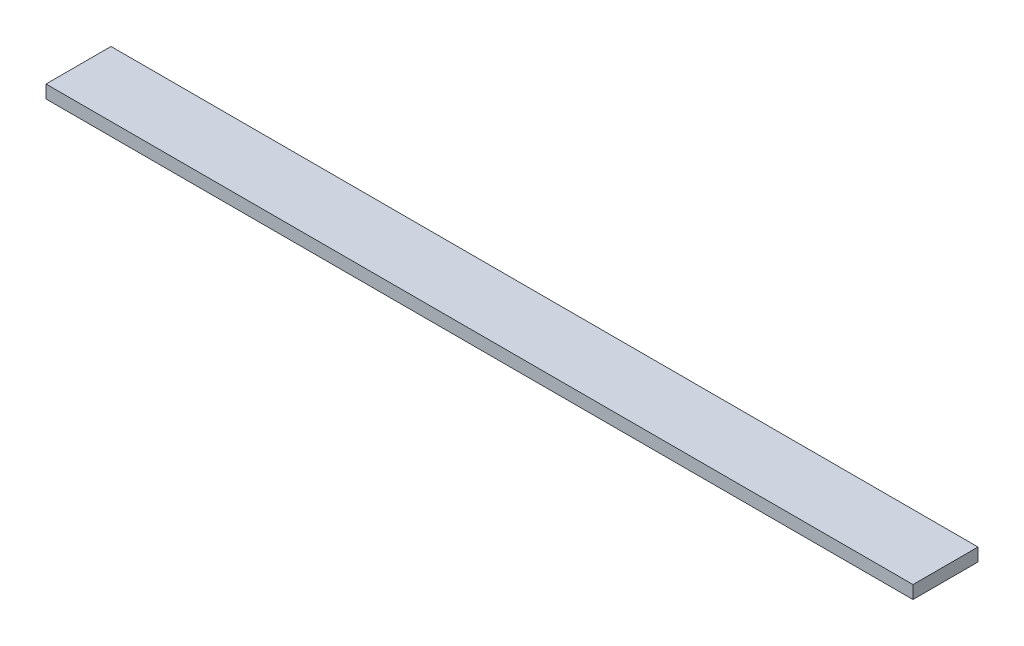
from build123d import *

# Parameters (mm, degrees)
SKETCH_1_W      = 15
SKETCH_1_H      = 3
EXTRUDE_1_DEPTH = 200


with BuildPart() as part:
    # Эскиз1 → Бобышка-Вытянуть1 (new body)
    with BuildSketch(Plane(origin=(0, 0, 0), x_dir=(0, 0, -1), z_dir=(1, 0, 0))):
        Rectangle(SKETCH_1_W, SKETCH_1_H)
    extrude(amount=EXTRUDE_1_DEPTH)


solid = part.part
